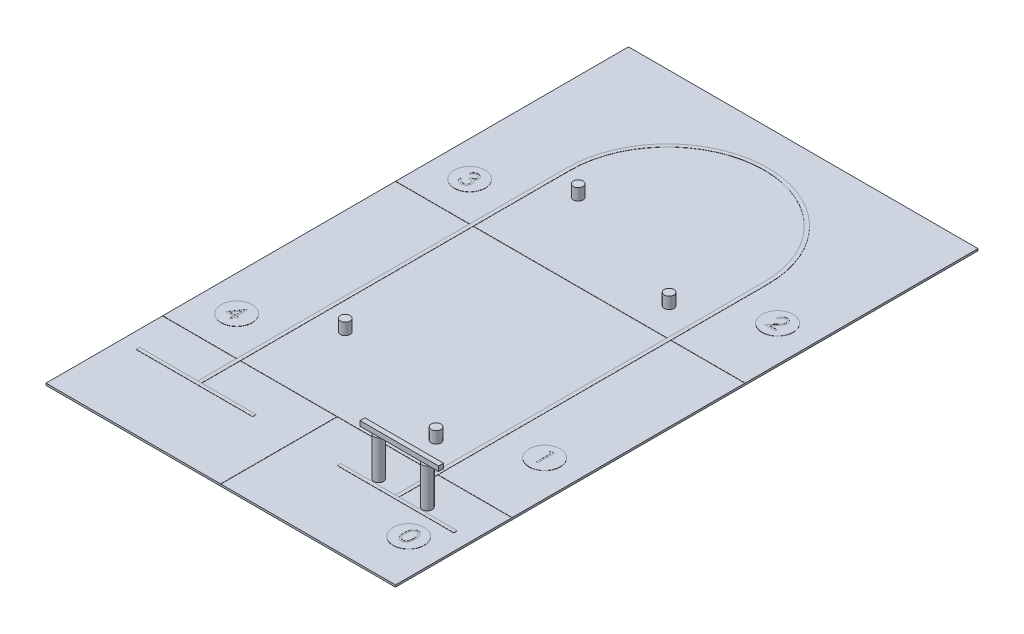
from build123d import *

# Parameters (mm, degrees)
EXTRUDE_1_DEPTH       = 1
SKETCH_2_W            = 1800
SKETCH_2_H            = 3000
EXTRUDE_1_2_DEPTH     = 10
SKETCH_3_W            = 600
SKETCH_3_H            = 18
EXTRUDE_2_DEPTH       = 1
EXTRUDE_2_2_DEPTH     = 1
SKETCH_4_R            = 80
EXTRUDE_2_3_DEPTH     = 1
EXTRUDE_2_3_2_DEPTH   = 1
EXTRUDE_2_3_3_DEPTH   = 1
EXTRUDE_2_3_4_DEPTH   = 1
EXTRUDE_2_3_5_DEPTH   = 1
CUT_EXTRUDE_1_DEPTH   = 0.5
SKETCH_6_R            = 25
EXTRUDE_3_DEPTH       = 60
EXTRUDE_3_2_DEPTH     = 60
EXTRUDE_3_3_DEPTH     = 60
EXTRUDE_3_4_DEPTH     = 60
SKETCH_8_R            = 24.990921926
EXTRUDE_5_DEPTH       = 200
SKETCH_8_R_2          = 25.210760771
EXTRUDE_5_2_DEPTH     = 200
SKETCH_7_W            = 404.461770461
SKETCH_7_H            = 25
EXTRUDE_4_DEPTH       = 25
SKETCH_9_W            = 1800
SKETCH_9_H            = 2
CUT_EXTRUDE_1_2_DEPTH = 1
SKETCH_10_W           = 2
SKETCH_10_H           = 599
CUT_EXTRUDE_2_DEPTH   = 1


with BuildPart() as part:
    # 草圖1 → Extrude 1 (new body)
    with BuildSketch(Plane(origin=(0, 0, 0), x_dir=(1, 0, 0), z_dir=(0, 1, 0))):
        with BuildLine():
            Line((499, 0), (499, 1900))
            ThreePointArc((499, 1900), (0, 2399), (-499, 1900))
            Line((-499, 1900), (-499, 0))
            Line((-499, 0), (-518, 0))
            Line((-518, 0), (-518, 1900))
            ThreePointArc((-518, 1900), (0, 2418), (518, 1900))
            Line((518, 1900), (518, 0))
            Line((518, 0), (499, 0))
        make_face()
    extrude(amount=EXTRUDE_1_DEPTH)


with BuildPart() as body_2:
    # 草圖2 → Extrude 1 2 (new body)
    with BuildSketch(Plane(origin=(0, 0, 0), x_dir=(-1, 0, 0), z_dir=(0, -1, 0))):
        with Locations((0, 1100)):
            Rectangle(SKETCH_2_W, SKETCH_2_H)
    extrude(amount=EXTRUDE_1_2_DEPTH)

    # 草圖9 → Cut-Extrude 1 2 (cut)
    with BuildSketch(Plane(origin=(0, 0, 0), x_dir=(1, 0, 0), z_dir=(0, 1, 0))):
        with Locations((0, 1400)):
            Rectangle(SKETCH_9_W, SKETCH_9_H)
        with Locations((0, 200)):
            Rectangle(SKETCH_9_W, SKETCH_9_H)
    extrude(amount=-CUT_EXTRUDE_1_2_DEPTH, mode=Mode.SUBTRACT)

    # 草圖10 → 除料-伸長-薄件2 (cut)
    with BuildSketch(Plane(origin=(0, 0, 0), x_dir=(1, 0, 0), z_dir=(0, 1, 0))):
        with Locations((0, -100.5)):
            Rectangle(SKETCH_10_W, SKETCH_10_H)
    extrude(amount=-CUT_EXTRUDE_2_DEPTH, mode=Mode.SUBTRACT)


with BuildPart() as body_3:
    # 草圖3 → Extrude 2 (new body)
    with BuildSketch(Plane(origin=(0, 0, 0), x_dir=(1, 0, 0), z_dir=(0, 1, 0))):
        with Locations((518, -9)):
            Rectangle(SKETCH_3_W, SKETCH_3_H)
    extrude(amount=EXTRUDE_2_DEPTH)


with BuildPart() as body_4:
    # 草圖3 → Extrude 2 2 (new body)
    with BuildSketch(Plane(origin=(0, 0, 0), x_dir=(1, 0, 0), z_dir=(0, 1, 0))):
        with Locations((-518, -9)):
            Rectangle(SKETCH_3_W, SKETCH_3_H)
    extrude(amount=EXTRUDE_2_2_DEPTH)


with BuildPart() as body_5:
    # 草圖4 → Extrude 2 3 (new body)
    with BuildSketch(Plane(origin=(0, 0, 0), x_dir=(1, 0, 0), z_dir=(0, 1, 0))):
        with Locations((718, 550)):
            Circle(SKETCH_4_R)
    extrude(amount=EXTRUDE_2_3_DEPTH)


with BuildPart() as body_6:
    # 草圖4 → Extrude 2 3 2 (new body)
    with BuildSketch(Plane(origin=(0, 0, 0), x_dir=(1, 0, 0), z_dir=(0, 1, 0))):
        with Locations((718, 1750)):
            Circle(SKETCH_4_R)
    extrude(amount=EXTRUDE_2_3_2_DEPTH)


with BuildPart() as body_7:
    # 草圖4 → Extrude 2 3 3 (new body)
    with BuildSketch(Plane(origin=(0, 0, 0), x_dir=(1, 0, 0), z_dir=(0, 1, 0))):
        with Locations((-718, 1600)):
            Circle(SKETCH_4_R)
    extrude(amount=EXTRUDE_2_3_3_DEPTH)


with BuildPart() as body_8:
    # 草圖4 → Extrude 2 3 4 (new body)
    with BuildSketch(Plane(origin=(0, 0, 0), x_dir=(1, 0, 0), z_dir=(0, 1, 0))):
        with Locations((-718, 400)):
            Circle(SKETCH_4_R)
    extrude(amount=EXTRUDE_2_3_4_DEPTH)


with BuildPart() as body_9:
    # 草圖4 → Extrude 2 3 5 (new body)
    with BuildSketch(Plane(origin=(0, 0, 0), x_dir=(1, 0, 0), z_dir=(0, 1, 0))):
        with Locations((718, -150)):
            Circle(SKETCH_4_R)
    extrude(amount=EXTRUDE_2_3_5_DEPTH)


with BuildPart() as cut_extrude_1_tool:
    # 草圖5 → Cut-Extrude 1 (new body)
    with BuildSketch(Plane(origin=(0, 1, 0), x_dir=(1, 0, 0), z_dir=(0, 1, 0))):
        Polygon((707.122974179, 595.959229012), (722.792775679, 595.959229012), (722.792775679, 511.209880054), (715.187064876, 511.209880054), (715.187064876, 587.266988093), (702.148703497, 587.266988093), align=None)
        with BuildLine():
            Line((699.764246473, 1769.474392526), (692.158535669, 1769.474392526))
            add(Edge.make_bspline(
                [(692.158535669, 1769.474392526), (692.208105636, 1770.483415558), (692.305459732, 1772.465109937), (692.761369806, 1775.354430904), (693.413718893, 1778.116165171), (694.336069158, 1780.728138023), (695.481548084, 1783.213444335), (696.855214623, 1785.562212386), (698.482253219, 1787.765482101), (700.327530675, 1789.802828442), (702.331698754, 1791.671855977), (704.494161676, 1793.285852672), (706.766534523, 1794.649534381), (709.141923151, 1795.789564265), (711.647127552, 1796.645286818), (714.259413828, 1797.280220213), (716.990259081, 1797.662230222), (718.850871036, 1797.703292143), (719.797145466, 1797.724175513)],
                knots=[0, 0, 0, 0, 0.003028771, 0.005948426, 0.008760778, 0.011531313, 0.014243072, 0.016959663, 0.019679487, 0.022444295, 0.025195465, 0.027888025, 0.030522967, 0.03313528, 0.035776832, 0.038449192, 0.041191074, 0.044028729, 0.044028729, 0.044028729, 0.044028729], degree=3))
            add(Edge.make_bspline(
                [(719.797145466, 1797.724175513), (720.726435978, 1797.702420199), (722.552458639, 1797.659671784), (725.217511231, 1797.29256111), (727.754599085, 1796.717582986), (730.158762963, 1795.910880174), (732.410821084, 1794.826465584), (734.527691401, 1793.523806619), (736.534575617, 1792.017209419), (738.341111714, 1790.243434276), (739.999973175, 1788.349833942), (741.431081073, 1786.32824952), (742.65663326, 1784.240284998), (743.678169947, 1782.070018789), (744.430166391, 1779.797016348), (745.001091471, 1777.454369934), (745.323802795, 1775.017830727), (745.373330884, 1773.368691799), (745.398511297, 1772.530258474)],
                knots=[0, 0, 0, 0, 0.002786768, 0.0054759, 0.008053951, 0.010582617, 0.013065737, 0.01553483, 0.018030512, 0.020575935, 0.023115293, 0.025574327, 0.027993956, 0.030371347, 0.032755034, 0.035163918, 0.037596141, 0.040111551, 0.040111551, 0.040111551, 0.040111551], degree=3))
            add(Edge.make_bspline(
                [(745.398511297, 1772.530258474), (745.357510461, 1771.349873548), (745.276228297, 1769.009817779), (744.58093552, 1765.571055733), (743.495017629, 1762.239354965), (742.187520246, 1759.557950891), (740.868519055, 1757.397242177), (739.679909252, 1755.618263631), (738.288450588, 1753.702795932), (736.673890791, 1751.657253262), (734.869628675, 1749.465613182), (732.859321734, 1747.129199656), (730.628634556, 1744.672152105), (729.062987172, 1742.993979363), (728.251707922, 1742.124392292)],
                knots=[0, 0, 0, 0, 0.003538113, 0.007014137, 0.010482275, 0.0140282, 0.015932354, 0.018074759, 0.020445047, 0.023032917, 0.025891368, 0.02896102, 0.032278543, 0.035846346, 0.035846346, 0.035846346, 0.035846346], degree=3))
            Line((728.251707922, 1742.124392292), (707.047393649, 1719.494007243))
            Line((707.047393649, 1719.494007243), (746.485041412, 1719.494007243))
            Line((746.485041412, 1719.494007243), (746.485041412, 1710.801766324))
            Line((746.485041412, 1710.801766324), (688.898945325, 1710.801766324))
            Line((688.898945325, 1710.801766324), (721.766481299, 1745.876316595))
            add(Edge.make_bspline(
                [(721.766481299, 1745.876316595), (722.566706125, 1746.711662029), (724.103774246, 1748.31618965), (726.277778512, 1750.658733332), (728.230379015, 1752.83193766), (729.974215344, 1754.831696578), (731.471458008, 1756.687261001), (732.800139703, 1758.338534353), (733.864726906, 1759.85807687), (735.020112255, 1761.619425347), (736.139142208, 1763.76993565), (737.100741157, 1766.397981223), (737.687081911, 1769.103356059), (737.757419888, 1770.931569912), (737.792800493, 1771.851177153)],
                knots=[0, 0, 0, 0, 0.00347034, 0.006665812, 0.009587096, 0.012235078, 0.014624078, 0.016739951, 0.018591148, 0.020187531, 0.023057805, 0.02583976, 0.028563396, 0.031320009, 0.031320009, 0.031320009, 0.031320009], degree=3))
            add(Edge.make_bspline(
                [(737.792800493, 1771.851177153), (737.777406566, 1772.429443715), (737.747068091, 1773.569096065), (737.479315901, 1775.240008394), (737.074686041, 1776.851815433), (736.494873175, 1778.40947503), (735.729544419, 1779.897326175), (734.797946162, 1781.317179967), (733.72308074, 1782.689852222), (732.479655985, 1783.976911481), (731.11370182, 1785.155683044), (729.670680719, 1786.199893948), (728.143979208, 1787.07254857), (726.540034285, 1787.787917756), (724.863317585, 1788.349088747), (723.11058615, 1788.73793279), (721.28668291, 1788.982071062), (720.041267117, 1789.015103257), (719.406673706, 1789.031934594)],
                knots=[0, 0, 0, 0, 0.001733737, 0.003416862, 0.005063897, 0.006713117, 0.008391098, 0.010072167, 0.011800909, 0.013613958, 0.015431452, 0.017207642, 0.018949092, 0.020696985, 0.022468626, 0.024243761, 0.026075787, 0.027979108, 0.027979108, 0.027979108, 0.027979108], degree=3))
            add(Edge.make_bspline(
                [(719.406673706, 1789.031934594), (718.743913633, 1789.014620731), (717.44236228, 1788.980619164), (715.531408948, 1788.742772199), (713.708431625, 1788.33244393), (711.968844624, 1787.771241625), (710.309704541, 1787.057929387), (708.739080112, 1786.169471823), (707.260497223, 1785.109293955), (705.871176366, 1783.907292575), (704.591122707, 1782.569037368), (703.466453424, 1781.07720758), (702.483748059, 1779.459041881), (701.626345349, 1777.718906489), (700.930052202, 1775.841011528), (700.397992147, 1773.832023251), (699.976985307, 1771.700664745), (699.83633721, 1770.22880864), (699.764246473, 1769.474392526)],
                knots=[0, 0, 0, 0, 0.001988126, 0.003904351, 0.005766028, 0.007586058, 0.009380571, 0.011174683, 0.012988367, 0.014829808, 0.016679136, 0.018533056, 0.0204227, 0.022351219, 0.024344195, 0.026419842, 0.028580732, 0.030852992, 0.030852992, 0.030852992, 0.030852992], degree=3))
        make_face()
        with BuildLine():
            Line((-736.887828238, 1623.595663929), (-744.493539042, 1623.595663929))
            add(Edge.make_bspline(
                [(-744.493539042, 1623.595663929), (-744.287487933, 1624.448786809), (-743.884674869, 1626.116572259), (-743.044504366, 1628.499415484), (-742.129229432, 1630.754317716), (-741.030173128, 1632.839056628), (-739.831363218, 1634.795529315), (-738.457873583, 1636.57936084), (-736.973071707, 1638.235919207), (-735.330751622, 1639.706035594), (-733.608435118, 1641.037271811), (-731.781853714, 1642.172309123), (-729.887756768, 1643.14872218), (-727.913021075, 1643.953120187), (-725.851767467, 1644.559090712), (-723.722630801, 1644.998741413), (-721.52003154, 1645.284252628), (-720.024869225, 1645.312117321), (-719.265667937, 1645.326266226)],
                knots=[0, 0, 0, 0, 0.002631221, 0.005143822, 0.007571538, 0.009925475, 0.012205523, 0.014446556, 0.016670029, 0.018869521, 0.021049467, 0.023192746, 0.025311137, 0.027435981, 0.029579193, 0.031746742, 0.03395356, 0.036230066, 0.036230066, 0.036230066, 0.036230066], degree=3))
            add(Edge.make_bspline(
                [(-719.265667937, 1645.326266226), (-718.159501466, 1645.292869407), (-715.971297225, 1645.226804251), (-712.756559569, 1644.623523603), (-709.656505407, 1643.668879517), (-706.705067008, 1642.349847257), (-703.963584593, 1640.722966957), (-701.524348523, 1638.786692845), (-699.42042146, 1636.578383866), (-697.655349731, 1634.139235511), (-696.273330014, 1631.532454273), (-695.25424637, 1628.849528221), (-694.633840432, 1626.096821631), (-694.553436138, 1624.23821322), (-694.513153758, 1623.307054367)],
                knots=[0, 0, 0, 0, 0.003315784, 0.006559242, 0.009775796, 0.013028527, 0.01623413, 0.019315029, 0.02234104, 0.02535665, 0.028318644, 0.031166032, 0.033946588, 0.036738265, 0.036738265, 0.036738265, 0.036738265], degree=3))
            add(Edge.make_bspline(
                [(-694.513153758, 1623.307054367), (-694.541329068, 1622.41096815), (-694.596463777, 1620.657466481), (-695.064612051, 1618.097515608), (-695.852448364, 1615.684783964), (-696.943772089, 1613.409114735), (-698.356460203, 1611.284936717), (-700.067735932, 1609.307470693), (-702.089677709, 1607.467945924), (-703.621920224, 1606.414161066), (-704.410764023, 1605.87164143)],
                knots=[0, 0, 0, 0, 0.002686719, 0.005257493, 0.007775422, 0.010281189, 0.012805006, 0.015405098, 0.018109354, 0.020978924, 0.020978924, 0.020978924, 0.020978924], degree=3))
            add(Edge.make_bspline(
                [(-704.410764023, 1605.87164143), (-703.509230606, 1605.436316192), (-701.723032158, 1604.573810987), (-699.288291611, 1602.88231671), (-697.078080036, 1600.929295873), (-695.845492309, 1599.4051962), (-695.226189146, 1598.639425353)],
                knots=[0, 0, 0, 0, 0.002999222, 0.005942327, 0.00886361, 0.011813562, 0.011813562, 0.011813562, 0.011813562], degree=3))
            add(Edge.make_bspline(
                [(-695.226189146, 1598.639425353), (-694.818391203, 1598.081102657), (-694.009473291, 1596.973600185), (-693.010991966, 1595.192981837), (-692.105163942, 1593.392627462), (-691.399317625, 1591.524281912), (-690.852711763, 1589.609600074), (-690.461992269, 1587.645294288), (-690.219266723, 1585.629760514), (-690.184506123, 1584.266204504), (-690.167033299, 1583.580797043)],
                knots=[0, 0, 0, 0, 0.002072311, 0.004110686, 0.006115127, 0.008114096, 0.010091611, 0.012082634, 0.014116834, 0.016172808, 0.016172808, 0.016172808, 0.016172808], degree=3))
            add(Edge.make_bspline(
                [(-690.167033299, 1583.580797043), (-690.210485828, 1582.394070768), (-690.297186398, 1580.02620297), (-691.072136245, 1576.527877656), (-692.273476201, 1573.108229263), (-693.979527474, 1569.837513639), (-696.058731894, 1566.777326493), (-698.532379527, 1564.039285472), (-701.372364314, 1561.685708775), (-704.539705336, 1559.719276216), (-707.971258015, 1558.147347176), (-711.641524512, 1557.056321762), (-715.497621196, 1556.3457348), (-718.141977588, 1556.269536203), (-719.486369367, 1556.230796808)],
                knots=[0, 0, 0, 0, 0.003556152, 0.007095568, 0.010698581, 0.014403932, 0.018128718, 0.021770559, 0.025435397, 0.029156892, 0.032925182, 0.036722159, 0.040618601, 0.044648206, 0.044648206, 0.044648206, 0.044648206], degree=3))
            add(Edge.make_bspline(
                [(-719.486369367, 1556.230796808), (-720.392444035, 1556.251819811), (-722.17529684, 1556.293186069), (-724.796315702, 1556.575972883), (-727.298157632, 1557.092459756), (-729.684205279, 1557.787484454), (-731.956578347, 1558.668677725), (-734.10834265, 1559.766029197), (-736.152736509, 1561.056919223), (-738.070467809, 1562.556585293), (-739.861307941, 1564.234170562), (-741.477665061, 1566.119456392), (-742.946487335, 1568.177592005), (-744.228445667, 1570.432482972), (-745.381931588, 1572.854988807), (-746.330663178, 1575.476128739), (-747.165700176, 1578.272470362), (-747.553936077, 1580.221166386), (-747.753129386, 1581.22098945)],
                knots=[0, 0, 0, 0, 0.002718235, 0.005348579, 0.007895643, 0.010372254, 0.012796644, 0.015195878, 0.017607333, 0.020038845, 0.022488838, 0.024956355, 0.027476572, 0.030062437, 0.032728047, 0.03551585, 0.038416886, 0.041473695, 0.041473695, 0.041473695, 0.041473695], degree=3))
            Line((-747.753129386, 1581.22098945), (-740.147418582, 1581.22098945))
            add(Edge.make_bspline(
                [(-740.147418582, 1581.22098945), (-739.949267547, 1580.568443356), (-739.563846573, 1579.299184522), (-738.907782539, 1577.472465439), (-738.160335121, 1575.797865443), (-737.358495897, 1574.263100208), (-736.516367138, 1572.853055008), (-735.57407726, 1571.605015053), (-734.601417575, 1570.464162849), (-733.868230294, 1569.821408969), (-733.509398662, 1569.506836649)],
                knots=[0, 0, 0, 0, 0.002045785, 0.00397923, 0.005818478, 0.007542212, 0.009172714, 0.010738011, 0.012229673, 0.013659478, 0.013659478, 0.013659478, 0.013659478], degree=3))
            add(Edge.make_bspline(
                [(-733.509398662, 1569.506836649), (-733.034885204, 1569.141001946), (-732.087323003, 1568.410461788), (-730.543232698, 1567.478179516), (-728.919316859, 1566.670372323), (-727.180389178, 1566.053307574), (-725.363974047, 1565.530823944), (-723.440711906, 1565.188908286), (-721.427570614, 1564.954317939), (-720.052990329, 1564.933616543), (-719.350553103, 1564.923037727)],
                knots=[0, 0, 0, 0, 0.001796199, 0.003586854, 0.005401491, 0.007227608, 0.009114198, 0.01106545, 0.01308086, 0.015187107, 0.015187107, 0.015187107, 0.015187107], degree=3))
            add(Edge.make_bspline(
                [(-719.350553103, 1564.923037727), (-718.557456524, 1564.937951318), (-717.00662463, 1564.967113558), (-714.743699348, 1565.235301828), (-712.590885549, 1565.625885267), (-710.572085212, 1566.229130717), (-708.660854037, 1566.974461323), (-706.883983457, 1567.910297666), (-705.218147682, 1569.008279276), (-703.684683145, 1570.256253602), (-702.305798949, 1571.622449309), (-701.091715776, 1573.051397697), (-700.059597973, 1574.53707387), (-699.227030583, 1576.087699315), (-698.569604451, 1577.696852853), (-698.122050389, 1579.369050232), (-697.810862521, 1581.090606524), (-697.785519749, 1582.260848997), (-697.772744103, 1582.850784622)],
                knots=[0, 0, 0, 0, 0.0023783, 0.00465056, 0.006828125, 0.008933962, 0.010961065, 0.012973399, 0.014946317, 0.016937557, 0.01889434, 0.020761582, 0.022555774, 0.024310414, 0.026031721, 0.02775746, 0.029496259, 0.03126391, 0.03126391, 0.03126391, 0.03126391], degree=3))
            add(Edge.make_bspline(
                [(-697.772744103, 1582.850784622), (-697.809798977, 1583.640438833), (-697.883724344, 1585.215818045), (-698.448120611, 1587.533532932), (-699.376461691, 1589.766639835), (-700.676093231, 1591.877038826), (-702.258139079, 1593.832954559), (-704.107246547, 1595.578100621), (-706.238770846, 1597.018115336), (-708.200594032, 1598.013040158), (-709.938322687, 1598.691932692), (-711.425440929, 1599.144130143), (-713.090320179, 1599.527043579), (-714.912827055, 1599.883287988), (-716.906693907, 1600.186481161), (-719.069750039, 1600.439320328), (-721.402433775, 1600.641630123), (-723.017300315, 1600.731975236), (-723.849466859, 1600.778531517)],
                knots=[0, 0, 0, 0, 0.002367185, 0.004722592, 0.007112437, 0.009596021, 0.012130778, 0.014641141, 0.017193405, 0.019820406, 0.02122335, 0.022786067, 0.024478499, 0.026346359, 0.028356041, 0.03052711, 0.032878782, 0.035379079, 0.035379079, 0.035379079, 0.035379079], degree=3))
            Line((-723.849466859, 1600.778531517), (-723.849466859, 1609.470772436))
            add(Edge.make_bspline(
                [(-723.849466859, 1609.470772436), (-722.800968115, 1609.488565046), (-720.747216643, 1609.5234164), (-717.747227595, 1609.944935699), (-714.878503003, 1610.528026428), (-712.204618863, 1611.421168151), (-709.767500883, 1612.45850737), (-707.653135332, 1613.665633742), (-705.891144373, 1615.007452005), (-704.490090619, 1616.504672973), (-703.436069536, 1618.110432144), (-702.66541229, 1619.784029784), (-702.210179316, 1621.540134627), (-702.149409991, 1622.738603451), (-702.118864562, 1623.341008433)],
                knots=[0, 0, 0, 0, 0.003142999, 0.006156362, 0.009073252, 0.011913292, 0.014597274, 0.017008371, 0.019198672, 0.021216726, 0.023128434, 0.024936707, 0.026723736, 0.028529777, 0.028529777, 0.028529777, 0.028529777], degree=3))
            add(Edge.make_bspline(
                [(-702.118864562, 1623.341008433), (-702.128899151, 1623.783587576), (-702.148862488, 1624.664077791), (-702.400623209, 1625.950453501), (-702.778945295, 1627.197502541), (-703.299057602, 1628.399921709), (-703.99521778, 1629.549371654), (-704.828327768, 1630.655652098), (-705.820333433, 1631.712446914), (-706.957075168, 1632.697484228), (-708.177751639, 1633.636246402), (-709.515575201, 1634.43322049), (-710.9302083, 1635.114727829), (-712.423217116, 1635.676725027), (-713.999446777, 1636.099485972), (-715.651491447, 1636.403030086), (-717.382501343, 1636.592811839), (-718.563464924, 1636.620135414), (-719.163805739, 1636.634025307)],
                knots=[0, 0, 0, 0, 0.001325949, 0.002637912, 0.003916047, 0.005231301, 0.006556054, 0.007937989, 0.009379338, 0.01089496, 0.012446665, 0.013992693, 0.015556885, 0.017152456, 0.018770982, 0.020445868, 0.022187566, 0.023988412, 0.023988412, 0.023988412, 0.023988412], degree=3))
            add(Edge.make_bspline(
                [(-719.163805739, 1636.634025307), (-720.128778001, 1636.600334729), (-722.013593265, 1636.534529194), (-724.730776451, 1635.958160653), (-727.256775205, 1635.038555553), (-729.187575228, 1633.9408573), (-730.61336375, 1632.857265833), (-731.632218926, 1631.910921033), (-732.632757885, 1630.859234311), (-733.549156878, 1629.637430181), (-734.475926765, 1628.328251532), (-735.319656452, 1626.865146483), (-736.139538416, 1625.286280779), (-736.633567786, 1624.170116488), (-736.887828238, 1623.595663929)],
                knots=[0, 0, 0, 0, 0.002892131, 0.005649005, 0.008291757, 0.010930252, 0.012274872, 0.013656702, 0.015098051, 0.016622774, 0.018233357, 0.019907554, 0.021684312, 0.023568457, 0.023568457, 0.023568457, 0.023568457], degree=3))
        make_face()
        Polygon((-708.882591497, 447.841562694), (-707.33768149, 447.841562694), (-707.33768149, 389.168936492), (-697.558910456, 389.168936492), (-697.558910456, 380.476695573), (-707.33768149, 380.476695573), (-707.33768149, 360.919153506), (-714.943392294, 360.919153506), (-714.943392294, 380.476695573), (-755.145006543, 380.476695573), align=None)
        Polygon((-714.943392294, 389.168936492), (-714.943392294, 425.975144133), (-740.205217464, 389.168936492), align=None, mode=Mode.SUBTRACT)
        with BuildLine():
            add(Edge.make_bspline(
                [(690.811845822, -146.493090385), (690.819788487, -145.134742645), (690.835217227, -142.496132582), (691.006856958, -138.651305428), (691.291986271, -135.044366138), (691.682738226, -131.675142064), (692.158254237, -128.542763401), (692.793038643, -125.655601103), (693.514928818, -123.000292456), (694.351585186, -120.568178679), (695.295639397, -118.326492948), (696.323146817, -116.233784507), (697.474885491, -114.293219767), (698.685031444, -112.473825819), (700.002570771, -110.805384883), (701.390009396, -109.264335107), (702.901498932, -107.886292522), (704.485658177, -106.630880986), (706.156829727, -105.530362948), (707.867378288, -104.561006224), (709.629077675, -103.732887228), (711.446737712, -103.081759533), (713.304021096, -102.543943875), (715.207420446, -102.176157182), (717.160078473, -101.944745247), (718.478086662, -101.922621606), (719.146513974, -101.91140161)],
                knots=[0, 0, 0, 0, 0.004074806, 0.00791537, 0.011542977, 0.014927032, 0.018089366, 0.021043029, 0.023790215, 0.026340446, 0.028752499, 0.031083366, 0.033328254, 0.035517764, 0.037633637, 0.039700656, 0.041731169, 0.043762178, 0.045758622, 0.047727519, 0.049656711, 0.051590155, 0.053514036, 0.055451799, 0.057399724, 0.059404165, 0.059404165, 0.059404165, 0.059404165], degree=3))
            add(Edge.make_bspline(
                [(719.146513974, -101.91140161), (719.820525025, -101.923213615), (721.160920943, -101.946703977), (723.142611949, -102.172474851), (725.078521514, -102.547094169), (726.960396273, -103.077890833), (728.803694285, -103.736409659), (730.593997831, -104.561798511), (732.342427305, -105.522586561), (734.0211978, -106.651541775), (735.648739197, -107.910245793), (737.185074499, -109.333130914), (738.630343548, -110.905829892), (740.002685043, -112.611516208), (741.263164463, -114.482904957), (742.463540494, -116.487447646), (743.537969396, -118.660199753), (744.572751081, -120.964909091), (745.465936256, -123.465345621), (746.271448435, -126.147414575), (746.92229846, -129.042795858), (747.464434533, -132.136298319), (747.884425573, -135.439282718), (748.190313628, -138.944668716), (748.351896374, -142.654762531), (748.382326262, -145.191379536), (748.397941909, -146.493090385)],
                knots=[0, 0, 0, 0, 0.002021408, 0.004019944, 0.005974369, 0.00793093, 0.009880335, 0.011840355, 0.013838891, 0.015858873, 0.017903249, 0.020005729, 0.0221322, 0.024306321, 0.026566563, 0.028895822, 0.031310204, 0.033833793, 0.036470704, 0.039269238, 0.042230307, 0.045367523, 0.048688302, 0.05221581, 0.055920694, 0.059826003, 0.059826003, 0.059826003, 0.059826003], degree=3))
            add(Edge.make_bspline(
                [(748.397941909, -146.493090385), (748.382164376, -147.789123628), (748.351422496, -150.314391549), (748.192125035, -154.007791793), (747.878343448, -157.494574771), (747.485833174, -160.783102849), (746.942203319, -163.859688699), (746.273769071, -166.734978614), (745.531599098, -169.421389426), (744.615463621, -171.896913348), (743.612740552, -174.196083832), (742.52176954, -176.343079002), (741.352959158, -178.356875905), (740.079570044, -180.221355454), (738.722287108, -181.949725373), (737.252060516, -183.511477239), (735.71033462, -184.944241789), (734.078003662, -186.219153546), (732.373051341, -187.3350556), (730.630627077, -188.333011883), (728.819814777, -189.137711674), (726.981650971, -189.828662001), (725.089842924, -190.356540317), (723.146748819, -190.721540157), (721.162252351, -190.97752795), (719.820753331, -190.997056134), (719.146513974, -191.006871027)],
                knots=[0, 0, 0, 0, 0.003888334, 0.007576259, 0.011086854, 0.014388658, 0.017509154, 0.020453679, 0.023242722, 0.025863681, 0.0283649, 0.030764134, 0.033084777, 0.035345018, 0.037532422, 0.03967045, 0.041772931, 0.043841135, 0.045875264, 0.047882075, 0.049857549, 0.051812784, 0.053769346, 0.055740437, 0.057740919, 0.059762327, 0.059762327, 0.059762327, 0.059762327], degree=3))
            add(Edge.make_bspline(
                [(719.146513974, -191.006871027), (718.478105205, -190.99557865), (717.16013358, -190.973312285), (715.20720771, -190.742945843), (713.311668819, -190.372579003), (711.464163182, -189.853995216), (709.655212177, -189.219226556), (707.909465504, -188.392225856), (706.207512523, -187.439786789), (704.553893977, -186.355105988), (702.979683028, -185.112397635), (701.476021207, -183.73790149), (700.080683249, -182.197317865), (698.781981911, -180.514972508), (697.547690257, -178.706342891), (696.412306296, -176.746735197), (695.362120112, -174.643919568), (694.402188676, -172.384310375), (693.551095433, -169.934934867), (692.799303134, -167.267771676), (692.20571488, -164.359279688), (691.697631508, -161.232818887), (691.28782281, -157.874954511), (691.008045224, -154.283863611), (690.83512471, -150.461783985), (690.819747052, -147.840128875), (690.811845822, -146.493090385)],
                knots=[0, 0, 0, 0, 0.002004441, 0.003952366, 0.005890129, 0.007793071, 0.009704779, 0.011633971, 0.013579749, 0.015552667, 0.017559838, 0.019590351, 0.02165737, 0.023786617, 0.025962064, 0.028221604, 0.030575236, 0.033009531, 0.03558137, 0.038349459, 0.041316168, 0.04448119, 0.047850393, 0.051461078, 0.055284681, 0.059325536, 0.059325536, 0.059325536, 0.059325536], degree=3))
        make_face()
        with BuildLine():
            add(Edge.make_bspline(
                [(698.417556626, -146.459136319), (698.42044893, -147.591113972), (698.426062322, -149.788060323), (698.572707767, -152.98052619), (698.772479707, -155.958141992), (699.030149138, -158.724688515), (699.412803309, -161.270801402), (699.841557235, -163.613992156), (700.363324825, -165.741860337), (700.98066373, -167.66900752), (701.683819317, -169.428139308), (702.451548261, -171.065041871), (703.276298002, -172.599051976), (704.199318914, -174.016390606), (705.204568794, -175.321679837), (706.269341675, -176.538022647), (707.433376023, -177.62274122), (709.043704275, -178.923688644), (711.16961686, -180.268034484), (713.848191592, -181.438691523), (716.600570798, -182.174375352), (718.468718859, -182.267932724), (719.401169469, -182.314630109)],
                knots=[0, 0, 0, 0, 0.003395576, 0.006590147, 0.009585042, 0.012348703, 0.014922501, 0.017306551, 0.019492966, 0.021490204, 0.023372283, 0.025172248, 0.02691196, 0.028593029, 0.030239888, 0.031851366, 0.033436697, 0.035006315, 0.038058406, 0.040947496, 0.043751586, 0.046545946, 0.046545946, 0.046545946, 0.046545946], degree=3))
            add(Edge.make_bspline(
                [(719.401169469, -182.314630109), (720.339651595, -182.275941285), (722.214678231, -182.198643515), (724.954111226, -181.452879818), (727.613552337, -180.327661756), (729.69770688, -178.997157381), (731.283307717, -177.730073995), (732.419360393, -176.649770452), (733.462069127, -175.440134101), (734.4510232, -174.135011175), (735.358060993, -172.709466974), (736.182869206, -171.170356439), (736.935524482, -169.513405503), (737.364333086, -168.356704277), (737.58357186, -167.76531279)],
                knots=[0, 0, 0, 0, 0.002809891, 0.005613981, 0.008458432, 0.011449331, 0.01299508, 0.014544089, 0.016144349, 0.017780938, 0.01945281, 0.02120745, 0.023015723, 0.024907425, 0.024907425, 0.024907425, 0.024907425], degree=3))
            add(Edge.make_bspline(
                [(737.58357186, -167.76531279), (737.839073417, -167.009112764), (738.357851153, -165.473702411), (739.026445408, -163.091915132), (739.552990672, -160.592953117), (740.026699961, -157.99175063), (740.350032188, -155.269124499), (740.61028081, -152.433498843), (740.763572695, -149.482735668), (740.782574736, -147.477929497), (740.792231105, -146.459136319)],
                knots=[0, 0, 0, 0, 0.002394424, 0.004861707, 0.007415778, 0.010053399, 0.012790863, 0.015637441, 0.018595394, 0.021651684, 0.021651684, 0.021651684, 0.021651684], degree=3))
            add(Edge.make_bspline(
                [(740.792231105, -146.459136319), (740.778908769, -145.440507923), (740.75284743, -143.447853027), (740.653230921, -140.529613784), (740.395990629, -137.757880009), (740.110285589, -135.120710965), (739.689027543, -132.632704891), (739.234824137, -130.273033483), (738.62459947, -128.070930013), (737.972761354, -125.991917541), (737.226715365, -124.059616537), (736.405476394, -122.265017925), (735.528399116, -120.599457741), (734.575762183, -119.06750571), (733.558874526, -117.66229993), (732.450896668, -116.412014709), (731.295778228, -115.277899694), (729.677860229, -113.983351715), (727.559749054, -112.663400085), (724.924149697, -111.448681374), (722.181403024, -110.751114505), (720.327245772, -110.65276441), (719.401169469, -110.603642529)],
                knots=[0, 0, 0, 0, 0.00305629, 0.005978757, 0.008756202, 0.011405326, 0.013933993, 0.016324561, 0.018610164, 0.020784617, 0.022859152, 0.024819172, 0.026702629, 0.028502194, 0.030227181, 0.031899311, 0.033508103, 0.035077721, 0.038106398, 0.040971294, 0.043754751, 0.046532195, 0.046532195, 0.046532195, 0.046532195], degree=3))
            add(Edge.make_bspline(
                [(719.401169469, -110.603642529), (718.463827333, -110.65283218), (716.587435447, -110.751301095), (713.816181261, -111.446082399), (711.159789152, -112.657101342), (709.047279065, -113.987723568), (707.428232672, -115.255048659), (706.288167641, -116.354040783), (705.219207825, -117.556180136), (704.234476079, -118.873473526), (703.312178378, -120.28915976), (702.465144652, -121.814375989), (701.701980889, -123.456851405), (700.99772503, -125.215193013), (700.378502991, -127.142173936), (699.867731663, -129.267421097), (699.395870215, -131.603158962), (699.061830199, -134.163061668), (698.764874394, -136.930301124), (698.574034649, -139.915350399), (698.425571769, -143.113170473), (698.420281851, -145.32147599), (698.417556626, -146.459136319)],
                knots=[0, 0, 0, 0, 0.002811276, 0.005627673, 0.008508071, 0.011536747, 0.013095771, 0.014668782, 0.01628026, 0.017916849, 0.019597918, 0.021345811, 0.023145777, 0.025027855, 0.027025093, 0.029211509, 0.031582101, 0.034170305, 0.036952571, 0.039930528, 0.043142061, 0.046554613, 0.046554613, 0.046554613, 0.046554613], degree=3))
        make_face(mode=Mode.SUBTRACT)
    extrude(amount=-CUT_EXTRUDE_1_DEPTH)


with BuildPart() as body_5_1:
    add(body_5.part)

    # Cut-Extrude 1: cut by cut_extrude_1_tool
    add(cut_extrude_1_tool.part, mode=Mode.SUBTRACT)


with BuildPart() as body_6_1:
    add(body_6.part)

    # Cut-Extrude 1: cut by cut_extrude_1_tool
    add(cut_extrude_1_tool.part, mode=Mode.SUBTRACT)


with BuildPart() as body_7_1:
    add(body_7.part)

    # Cut-Extrude 1: cut by cut_extrude_1_tool
    add(cut_extrude_1_tool.part, mode=Mode.SUBTRACT)


with BuildPart() as body_8_1:
    add(body_8.part)

    # Cut-Extrude 1: cut by cut_extrude_1_tool
    add(cut_extrude_1_tool.part, mode=Mode.SUBTRACT)


with BuildPart() as body_9_1:
    add(body_9.part)

    # Cut-Extrude 1: cut by cut_extrude_1_tool
    add(cut_extrude_1_tool.part, mode=Mode.SUBTRACT)


with BuildPart() as body_10:
    # 草圖6 → 填料-伸長3 (new body)
    with BuildSketch(Plane(origin=(0, 0, 0), x_dir=(1, 0, 0), z_dir=(0, 1, 0))):
        with Locations((359, 350)):
            Circle(SKETCH_6_R)
    extrude(amount=EXTRUDE_3_DEPTH)


with BuildPart() as body_11:
    # 草圖6 → Extrude 3 2 (new body)
    with BuildSketch(Plane(origin=(0, 0, 0), x_dir=(1, 0, 0), z_dir=(0, 1, 0))):
        with Locations((359, 1550)):
            Circle(SKETCH_6_R)
    extrude(amount=EXTRUDE_3_2_DEPTH)


with BuildPart() as body_12:
    # 草圖6 → Extrude 3 3 (new body)
    with BuildSketch(Plane(origin=(0, 0, 0), x_dir=(1, 0, 0), z_dir=(0, 1, 0))):
        with Locations((-359, 1800)):
            Circle(SKETCH_6_R)
    extrude(amount=EXTRUDE_3_3_DEPTH)


with BuildPart() as body_13:
    # 草圖6 → Extrude 3 4 (new body)
    with BuildSketch(Plane(origin=(0, 0, 0), x_dir=(1, 0, 0), z_dir=(0, 1, 0))):
        with Locations((-359, 600)):
            Circle(SKETCH_6_R)
    extrude(amount=EXTRUDE_3_4_DEPTH)


with BuildPart() as body_14:
    # 草圖8 → 填料-伸長5 (new body)
    with BuildSketch(Plane(origin=(0, 0, 0), x_dir=(1, 0, 0), z_dir=(0, 1, 0))):
        with Locations((383, 30)):
            Circle(SKETCH_8_R)
    extrude(amount=EXTRUDE_5_DEPTH)


with BuildPart() as body_15:
    # 草圖8 → Extrude 5 2 (new body)
    with BuildSketch(Plane(origin=(0, 0, 0), x_dir=(1, 0, 0), z_dir=(0, 1, 0))):
        with Locations((634, 30)):
            Circle(SKETCH_8_R_2)
    extrude(amount=EXTRUDE_5_2_DEPTH)


with BuildPart() as body_16:
    # 草圖7 → 填料-伸長4 (new body)
    with BuildSketch(Plane(origin=(0, 200, 0), x_dir=(1, 0, 0), z_dir=(0, 1, 0))):
        with Locations((503.084705026, 29.054069322)):
            Rectangle(SKETCH_7_W, SKETCH_7_H)
    extrude(amount=EXTRUDE_4_DEPTH)


solid = Compound([part.part, body_2.part, body_3.part, body_4.part, body_5_1.part, body_6_1.part, body_7_1.part, body_8_1.part, body_9_1.part, body_10.part, body_11.part, body_12.part, body_13.part, body_14.part, body_15.part, body_16.part])
